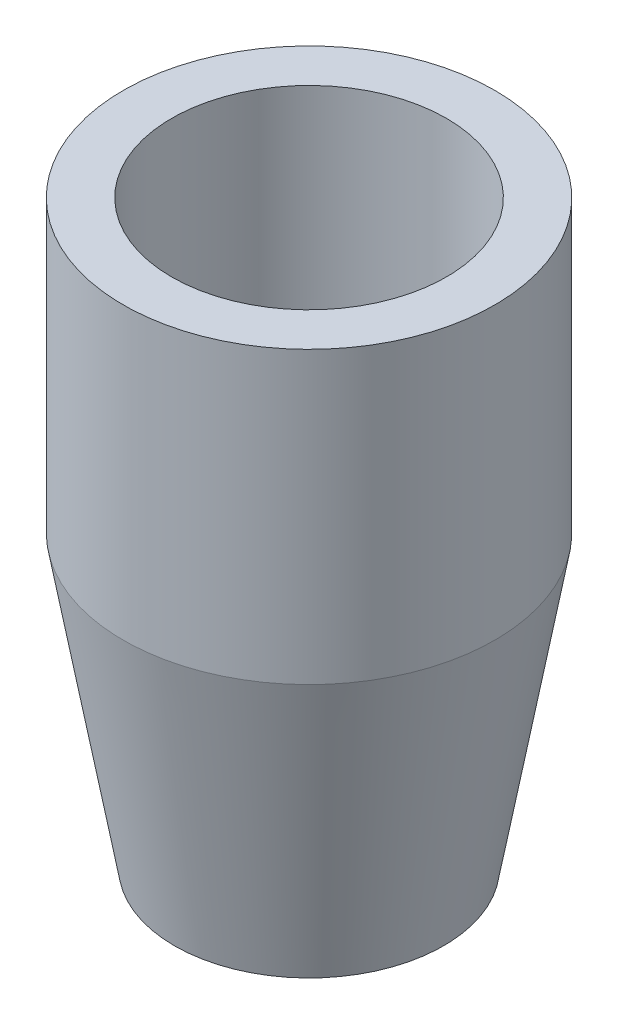
from build123d import *


with BuildPart() as part:
    # Sketch2 → Revolve2 (revolve)
    with BuildSketch(Plane.XY):
        Polygon((0, 0), (19.05, 0), (32.48611593, 76.2), (32.48611593, 152.4), (19.78611593, 152.4), (19.78611593, 76.2), (13.43611593, 76.2), (0, 50.8), align=None)
    revolve(axis=Axis((-16.28188407, 0, 0), (0, 1, 0)))


solid = part.part
